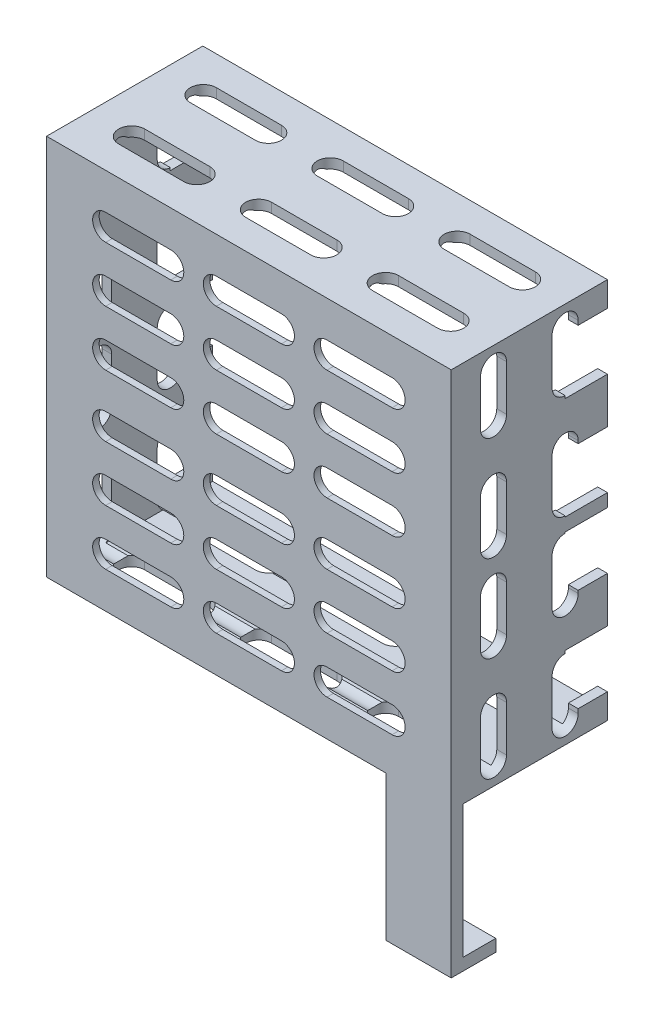
from build123d import *

# Parameters (mm, degrees)
BOSS_EXTRUDE1_DEPTH = 18
SKETCH2_W           = 62.16
SKETCH2_H           = 29.33
BOSS_EXTRUDE2_DEPTH = 1
BOSS_EXTRUDE3_DEPTH = 5
CUT_EXTRUDE4_DEPTH  = 2
CUT_EXTRUDE2_DEPTH  = 30.33
CUT_EXTRUDE3_DEPTH  = 63.16
SKETCH9_W           = 6.5
SKETCH9_H           = 8.75
CUT_EXTRUDE5_DEPTH  = 63.16
BOSS_EXTRUDE4_DEPTH = 10


with BuildPart() as part:
    # Sketch1 → Boss-Extrude1 (new body)
    with BuildSketch(Plane.XY):
        Polygon((29.58, 14.58), (29.58, -13.25), (31.08, -13.25), (31.08, 16.08), (-31.08, 16.08), (-31.08, -13.25), (-29.58, -13.25), (-29.58, 14.58), align=None)
    extrude(amount=BOSS_EXTRUDE1_DEPTH)

    # Sketch2 → Boss-Extrude2 (add)
    with BuildSketch(Plane.XY.offset(18)):
        with Locations((0, 1.415)):
            Rectangle(SKETCH2_W, SKETCH2_H)
    extrude(amount=BOSS_EXTRUDE2_DEPTH)

    # Sketch3 → Boss-Extrude3 (add)
    with BuildSketch(Plane(origin=(0, 0, 0), x_dir=(-1, 0, 0), z_dir=(0, 0, -1))):
        Polygon((-29.58, -13.25), (-29.58, 14.58), (29.58, 14.58), (29.58, -13.25), (31.08, -13.25), (31.08, 16.08), (-31.08, 16.08), (-31.08, -13.25), align=None)
    extrude(amount=BOSS_EXTRUDE3_DEPTH)

    # Sketch8 → Cut-Extrude4 (cut, through all)
    with BuildSketch(Plane(origin=(0, 0, 18), x_dir=(-1, 0, 0), z_dir=(0, 0, -1))):
        with BuildLine():
            Line((12, 6.5), (22, 6.5))
            ThreePointArc((22, 6.5), (24, 8.5), (22, 10.5))
            Line((22, 10.5), (12, 10.5))
            ThreePointArc((12, 10.5), (10, 8.5), (12, 6.5))
        make_face()
        with BuildLine():
            Line((12, -2), (22, -2))
            ThreePointArc((22, -2), (24, 0), (22, 2))
            Line((22, 2), (12, 2))
            ThreePointArc((12, 2), (10, 0), (12, -2))
        make_face()
        with BuildLine():
            Line((12, -10.5), (22, -10.5))
            ThreePointArc((22, -10.5), (24, -8.5), (22, -6.5))
            Line((22, -6.5), (12, -6.5))
            ThreePointArc((12, -6.5), (10, -8.5), (12, -10.5))
        make_face()
        with BuildLine():
            Line((-5, -10.5), (5, -10.5))
            ThreePointArc((5, -10.5), (7, -8.5), (5, -6.5))
            Line((5, -6.5), (-5, -6.5))
            ThreePointArc((-5, -6.5), (-7, -8.5), (-5, -10.5))
        make_face()
        with BuildLine():
            Line((-22, -10.5), (-12, -10.5))
            ThreePointArc((-12, -10.5), (-10, -8.5), (-12, -6.5))
            Line((-12, -6.5), (-22, -6.5))
            ThreePointArc((-22, -6.5), (-24, -8.5), (-22, -10.5))
        make_face()
        with BuildLine():
            Line((-22, -2), (-12, -2))
            ThreePointArc((-12, -2), (-10, 0), (-12, 2))
            Line((-12, 2), (-22, 2))
            ThreePointArc((-22, 2), (-24, 0), (-22, -2))
        make_face()
        with BuildLine():
            Line((-5, 6.5), (5, 6.5))
            ThreePointArc((5, 6.5), (7, 8.5), (5, 10.5))
            Line((5, 10.5), (-5, 10.5))
            ThreePointArc((-5, 10.5), (-7, 8.5), (-5, 6.5))
        make_face()
        with BuildLine():
            Line((-22, 6.5), (-12, 6.5))
            ThreePointArc((-12, 6.5), (-10, 8.5), (-12, 10.5))
            Line((-12, 10.5), (-22, 10.5))
            ThreePointArc((-22, 10.5), (-24, 8.5), (-22, 6.5))
        make_face()
        with BuildLine():
            Line((-5, -2), (5, -2))
            ThreePointArc((5, -2), (7, 0), (5, 2))
            Line((5, 2), (-5, 2))
            ThreePointArc((-5, 2), (-7, 0), (-5, -2))
        make_face()
    extrude(amount=-CUT_EXTRUDE4_DEPTH, mode=Mode.SUBTRACT)

    # Sketch5 → Cut-Extrude2 (cut, through all)
    with BuildSketch(Plane(origin=(-15, 16.08, 0), x_dir=(1, 0, 0), z_dir=(0, -1, 0))):
        with BuildLine():
            Line((-9.5, 3.5), (0.5, 3.5))
            ThreePointArc((0.5, 3.5), (2.5, 1.5), (0.5, -0.5))
            Line((0.5, -0.5), (-9.5, -0.5))
            ThreePointArc((-9.5, -0.5), (-11.5, 1.5), (-9.5, 3.5))
        make_face()
        with BuildLine():
            Line((10, -0.5), (20, -0.5))
            ThreePointArc((20, -0.5), (22, 1.5), (20, 3.5))
            Line((20, 3.5), (10, 3.5))
            ThreePointArc((10, 3.5), (8, 1.5), (10, -0.5))
        make_face()
        with BuildLine():
            Line((29.5, -0.5), (39.5, -0.5))
            ThreePointArc((39.5, -0.5), (41.5, 1.5), (39.5, 3.5))
            Line((39.5, 3.5), (29.5, 3.5))
            ThreePointArc((29.5, 3.5), (27.5, 1.5), (29.5, -0.5))
        make_face()
        with BuildLine():
            Line((10, 10.5), (20, 10.5))
            ThreePointArc((20, 10.5), (22, 12.5), (20, 14.5))
            Line((20, 14.5), (10, 14.5))
            ThreePointArc((10, 14.5), (8, 12.5), (10, 10.5))
        make_face()
        with BuildLine():
            Line((29.5, 10.5), (39.5, 10.5))
            ThreePointArc((39.5, 10.5), (41.5, 12.5), (39.5, 14.5))
            Line((39.5, 14.5), (29.5, 14.5))
            ThreePointArc((29.5, 14.5), (27.5, 12.5), (29.5, 10.5))
        make_face()
        with BuildLine():
            Line((-9.5, 10.5), (0.5, 10.5))
            ThreePointArc((0.5, 10.5), (2.5, 12.5), (0.5, 14.5))
            Line((0.5, 14.5), (-9.5, 14.5))
            ThreePointArc((-9.5, 14.5), (-11.5, 12.5), (-9.5, 10.5))
        make_face()
    extrude(amount=CUT_EXTRUDE2_DEPTH, mode=Mode.SUBTRACT)

    # Sketch7 → Cut-Extrude3 (cut, through all)
    with BuildSketch(Plane(origin=(31.08, -15, 0), x_dir=(0, 0, -1), z_dir=(-1, 0, 0))):
        with BuildLine():
            Line((-14.5, -27.915), (-14.5, -20.915))
            ThreePointArc((-14.5, -20.915), (-12.5, -18.915), (-10.5, -20.915))
            Line((-10.5, -20.915), (-10.5, -27.915))
            ThreePointArc((-10.5, -27.915), (-12.5, -29.915), (-14.5, -27.915))
        make_face()
        with BuildLine():
            Line((0.5, -27.915), (0.5, -20.915))
            ThreePointArc((0.5, -20.915), (-1.5, -18.915), (-3.5, -20.915))
            Line((-3.5, -20.915), (-3.5, -27.915))
            ThreePointArc((-3.5, -27.915), (-1.5, -29.915), (0.5, -27.915))
        make_face()
        with BuildLine():
            Line((0.5, -11.915), (0.5, -4.915))
            ThreePointArc((0.5, -4.915), (-1.5, -2.915), (-3.5, -4.915))
            Line((-3.5, -4.915), (-3.5, -11.915))
            ThreePointArc((-3.5, -11.915), (-1.5, -13.915), (0.5, -11.915))
        make_face()
        with BuildLine():
            Line((-10.5, -11.915), (-10.5, -4.915))
            ThreePointArc((-10.5, -4.915), (-12.5, -2.915), (-14.5, -4.915))
            Line((-14.5, -4.915), (-14.5, -11.915))
            ThreePointArc((-14.5, -11.915), (-12.5, -13.915), (-10.5, -11.915))
        make_face()
    extrude(amount=CUT_EXTRUDE3_DEPTH, mode=Mode.SUBTRACT)

    # Sketch9 → Cut-Extrude5 (cut, through all)
    with BuildSketch(Plane.ZY.offset(31.08)):
        with Locations((-1.75, 7.875)):
            Rectangle(SKETCH9_W, SKETCH9_H)
        with Locations((-1.75, -7.875)):
            Rectangle(SKETCH9_W, SKETCH9_H)
    extrude(amount=-CUT_EXTRUDE5_DEPTH, mode=Mode.SUBTRACT)

    # Mirror1: part across plane


with BuildPart() as part_1:
    add(part.part)
    add(part.part.mirror(Plane(origin=(0, -13.25, 18), x_dir=(0, 0, 1), z_dir=(0, -1, 0))))

    # Sketch10 → Boss-Extrude4 (add)
    with BuildSketch(Plane(origin=(31.08, 0, 0), x_dir=(0, 0, -1), z_dir=(1, 0, 0))):
        Polygon((-19, -42.58), (-19, -64.83), (-12.15, -64.83), (-12.15, -62.98), (-17.15, -62.98), (-17.15, -42.58), align=None)
    extrude(amount=-BOSS_EXTRUDE4_DEPTH)


solid = part_1.part
